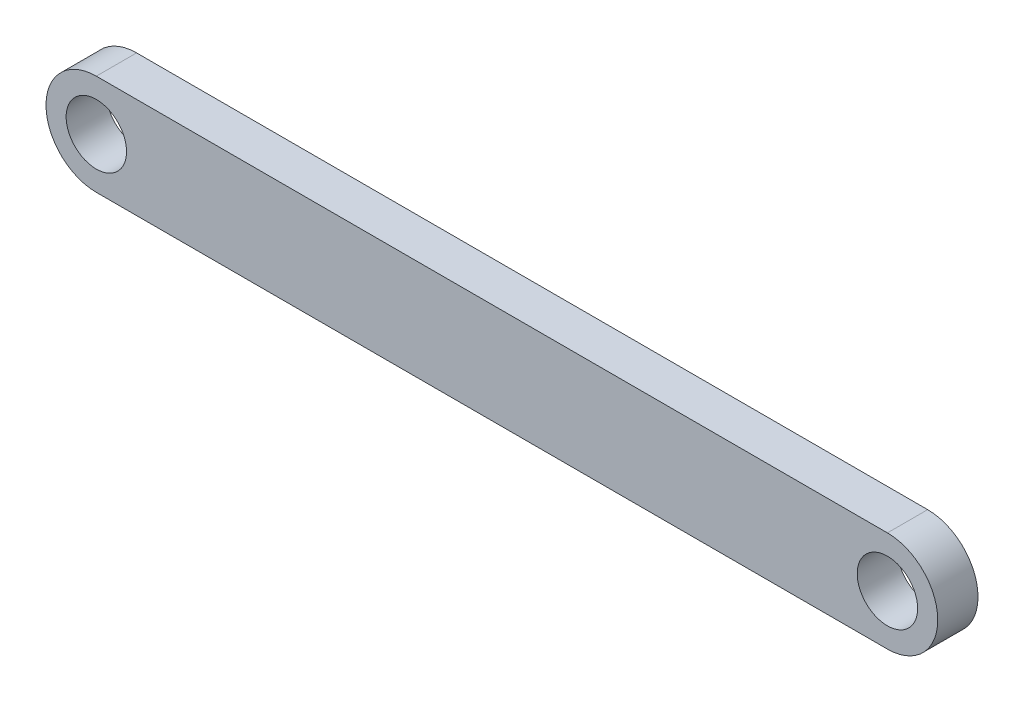
from build123d import *

# Parameters (mm, degrees)
SKETCH1_R           = 1.5
BOSS_EXTRUDE1_DEPTH = 2


with BuildPart() as part:
    # Sketch1 → Boss-Extrude1 (new body)
    with BuildSketch(Plane.XY):
        with BuildLine():
            Line((0.012911396, 2.564758055), (39.312911396, 2.564758055))
            ThreePointArc((39.312911396, 2.564758055), (41.812911396, 0.064758055), (39.312911396, -2.435241945))
            Line((39.312911396, -2.435241945), (0.012911396, -2.435241945))
            ThreePointArc((0.012911396, -2.435241945), (-2.487088604, 0.064758055), (0.012911396, 2.564758055))
        make_face()
        with Locations((0.012911396, 0.064758055)):
            Circle(SKETCH1_R, mode=Mode.SUBTRACT)
        with Locations((39.312911396, 0.064758055)):
            Circle(SKETCH1_R, mode=Mode.SUBTRACT)
    extrude(amount=BOSS_EXTRUDE1_DEPTH)


solid = part.part
